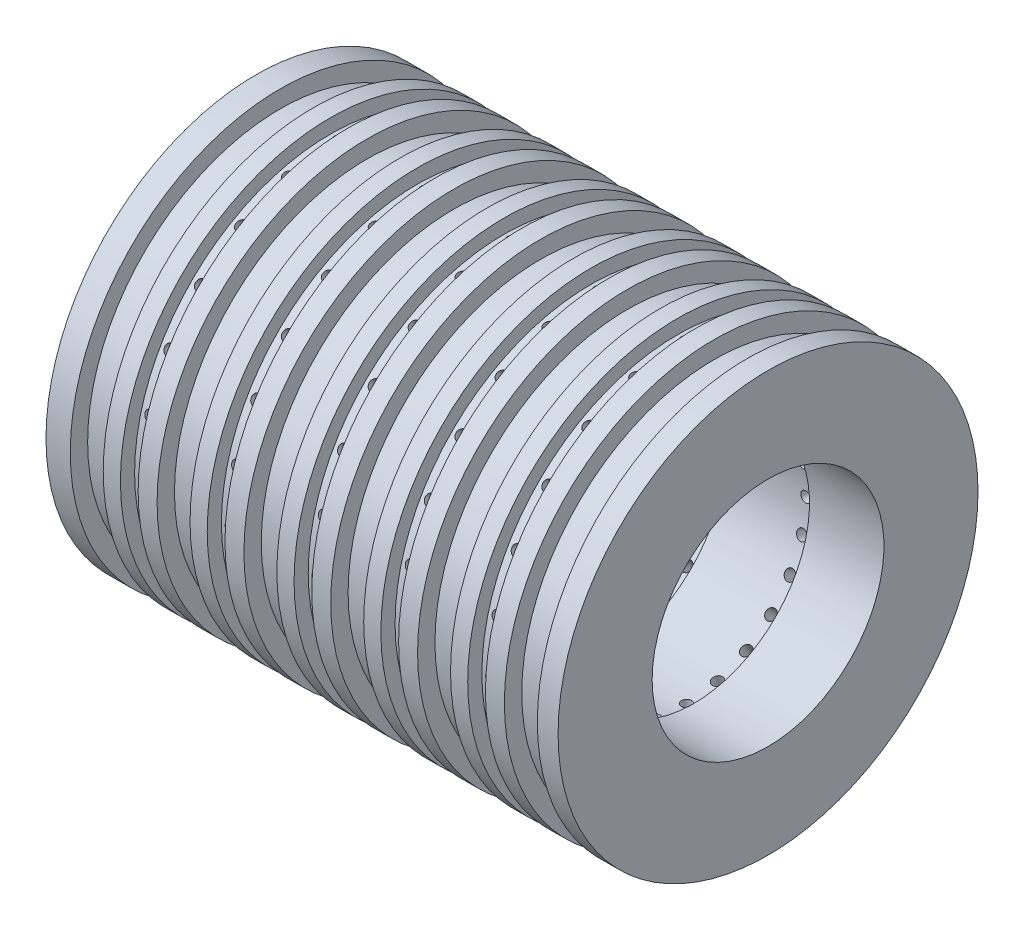
from build123d import *

# Parameters (mm, degrees)
F_69_0_0292_DIAMETER_HOLE1_REACH  = 47.36
F_69_0_0292_DIAMETER_HOLE1_BORE_R = 0.37084
CIRPATTERN1_COUNT                 = 24
CUT_EXTRUDE1_START                = -1.4859
SKETCH11_R                        = 17.8435
SKETCH11_R_2                      = 13.8049
CUT_EXTRUDE1_DEPTH                = 2.3622
LPATTERN1_COUNT                   = 6
LPATTERN1_PITCH                   = 6.223


with BuildPart() as part:
    # Sketch1 → Revolve1 (revolve)
    with BuildSketch(Plane.XY, mode=Mode.PRIVATE) as revolve1_sk:
        with BuildLine():
            Line((-6.477, 9.5758), (-6.477, 15.0495))
            Line((-6.477, 15.0495), (-3.937, 15.0495))
            ThreePointArc((-3.937, 15.0495), (-3.81, 15.1765), (-3.683, 15.0495))
            Line((-3.683, 15.0495), (-1.143, 15.0495))
            Line((-1.143, 15.0495), (-1.143, 14.0335))
            Line((-1.143, 14.0335), (0.127, 14.0335))
            Line((0.127, 14.0335), (0.127, 15.0495))
            Line((0.127, 15.0495), (2.4765, 15.0495))
            ThreePointArc((2.4765, 15.0495), (2.6035, 15.1765), (2.7305, 15.0495))
            Line((2.7305, 15.0495), (5.08, 15.0495))
            Line((5.08, 15.0495), (5.08, 14.0335))
            Line((5.08, 14.0335), (6.35, 14.0335))
            Line((6.35, 14.0335), (6.35, 15.0495))
            Line((6.35, 15.0495), (8.6995, 15.0495))
            ThreePointArc((8.6995, 15.0495), (8.8265, 15.1765), (8.9535, 15.0495))
            Line((8.9535, 15.0495), (11.303, 15.0495))
            Line((11.303, 15.0495), (11.303, 14.0335))
            Line((11.303, 14.0335), (12.573, 14.0335))
            Line((12.573, 14.0335), (12.573, 15.0495))
            Line((12.573, 15.0495), (14.9225, 15.0495))
            ThreePointArc((14.9225, 15.0495), (15.0495, 15.1765), (15.1765, 15.0495))
            Line((15.1765, 15.0495), (17.526, 15.0495))
            Line((17.526, 15.0495), (17.526, 14.0335))
            Line((17.526, 14.0335), (18.796, 14.0335))
            Line((18.796, 14.0335), (18.796, 15.0495))
            Line((18.796, 15.0495), (21.1455, 15.0495))
            ThreePointArc((21.1455, 15.0495), (21.2725, 15.1765), (21.3995, 15.0495))
            Line((21.3995, 15.0495), (23.749, 15.0495))
            Line((23.749, 15.0495), (23.749, 14.0335))
            Line((23.749, 14.0335), (25.019, 14.0335))
            Line((25.019, 14.0335), (25.019, 15.0495))
            Line((25.019, 15.0495), (27.4955, 15.0495))
            ThreePointArc((27.4955, 15.0495), (27.6225, 15.1765), (27.7495, 15.0495))
            Line((27.7495, 15.0495), (30.226, 15.0495))
            Line((30.226, 15.0495), (30.226, 8.3058))
            Line((30.226, 8.3058), (24.892, 8.3058))
            Line((24.892, 8.3058), (24.892, 8.5598))
            Line((24.892, 8.5598), (18.669, 8.5598))
            Line((18.669, 8.5598), (18.669, 8.8138))
            Line((18.669, 8.8138), (12.446, 8.8138))
            Line((12.446, 8.8138), (12.446, 9.0678))
            Line((12.446, 9.0678), (6.223, 9.0678))
            Line((6.223, 9.0678), (6.223, 9.3218))
            Line((6.223, 9.3218), (0, 9.3218))
            Line((0, 9.3218), (0, 9.5758))
            Line((0, 9.5758), (-6.477, 9.5758))
        make_face()
    revolve(revolve1_sk.sketch.rotate(Axis((0, 0, 0), (1, 0, 0)), 90), axis=Axis((0, 0, 0), (1, 0, 0)))

    # 69 _0.0292_ Diameter Hole1 bore → 69 _0.0292_ Diameter Hole1 (cut, up to next)
    with BuildSketch(Plane(origin=(0, 15.0495, 0), x_dir=(1, 0, 0), z_dir=(0, 1, 0)), mode=Mode.PRIVATE) as f_69_0_0292_diameter_hole1_sk1:
        with Locations((24.384, 0)):
            Circle(F_69_0_0292_DIAMETER_HOLE1_BORE_R)
    f_69_0_0292_diameter_hole1_tool1 = extrude(f_69_0_0292_diameter_hole1_sk1.sketch, amount=-F_69_0_0292_DIAMETER_HOLE1_REACH, mode=Mode.PRIVATE) & part.part
    # 69 _0.0292_ Diameter Hole1 bore → 69 _0.0292_ Diameter Hole1 (cut, up to next)
    with BuildSketch(Plane(origin=(0, 15.0495, 0), x_dir=(1, 0, 0), z_dir=(0, 1, 0)), mode=Mode.PRIVATE) as f_69_0_0292_diameter_hole1_sk2:
        with Locations((18.161, 0)):
            Circle(F_69_0_0292_DIAMETER_HOLE1_BORE_R)
    f_69_0_0292_diameter_hole1_tool2 = extrude(f_69_0_0292_diameter_hole1_sk2.sketch, amount=-F_69_0_0292_DIAMETER_HOLE1_REACH, mode=Mode.PRIVATE) & part.part
    # 69 _0.0292_ Diameter Hole1 bore → 69 _0.0292_ Diameter Hole1 (cut, up to next)
    with BuildSketch(Plane(origin=(0, 15.0495, 0), x_dir=(1, 0, 0), z_dir=(0, 1, 0)), mode=Mode.PRIVATE) as f_69_0_0292_diameter_hole1_sk3:
        with Locations((11.938, 0)):
            Circle(F_69_0_0292_DIAMETER_HOLE1_BORE_R)
    f_69_0_0292_diameter_hole1_tool3 = extrude(f_69_0_0292_diameter_hole1_sk3.sketch, amount=-F_69_0_0292_DIAMETER_HOLE1_REACH, mode=Mode.PRIVATE) & part.part
    # 69 _0.0292_ Diameter Hole1 bore → 69 _0.0292_ Diameter Hole1 (cut, up to next)
    with BuildSketch(Plane(origin=(0, 15.0495, 0), x_dir=(1, 0, 0), z_dir=(0, 1, 0)), mode=Mode.PRIVATE) as f_69_0_0292_diameter_hole1_sk4:
        with Locations((5.715, 0)):
            Circle(F_69_0_0292_DIAMETER_HOLE1_BORE_R)
    f_69_0_0292_diameter_hole1_tool4 = extrude(f_69_0_0292_diameter_hole1_sk4.sketch, amount=-F_69_0_0292_DIAMETER_HOLE1_REACH, mode=Mode.PRIVATE) & part.part
    # 69 _0.0292_ Diameter Hole1 bore → 69 _0.0292_ Diameter Hole1 (cut, up to next)
    with BuildSketch(Plane(origin=(0, 15.0495, 0), x_dir=(1, 0, 0), z_dir=(0, 1, 0)), mode=Mode.PRIVATE) as f_69_0_0292_diameter_hole1_sk5:
        with Locations((-0.508, 0)):
            Circle(F_69_0_0292_DIAMETER_HOLE1_BORE_R)
    f_69_0_0292_diameter_hole1_tool5 = extrude(f_69_0_0292_diameter_hole1_sk5.sketch, amount=-F_69_0_0292_DIAMETER_HOLE1_REACH, mode=Mode.PRIVATE) & part.part
    f_69_0_0292_diameter_hole1_1 = f_69_0_0292_diameter_hole1_tool1.solids().sort_by_distance((24.384, 15.0495, 0))[0]
    add(f_69_0_0292_diameter_hole1_1, mode=Mode.SUBTRACT)
    f_69_0_0292_diameter_hole1_2 = f_69_0_0292_diameter_hole1_tool2.solids().sort_by_distance((18.161, 15.0495, 0))[0]
    add(f_69_0_0292_diameter_hole1_2, mode=Mode.SUBTRACT)
    f_69_0_0292_diameter_hole1_3 = f_69_0_0292_diameter_hole1_tool3.solids().sort_by_distance((11.938, 15.0495, 0))[0]
    add(f_69_0_0292_diameter_hole1_3, mode=Mode.SUBTRACT)
    f_69_0_0292_diameter_hole1_4 = f_69_0_0292_diameter_hole1_tool4.solids().sort_by_distance((5.715, 15.0495, 0))[0]
    add(f_69_0_0292_diameter_hole1_4, mode=Mode.SUBTRACT)
    f_69_0_0292_diameter_hole1_5 = f_69_0_0292_diameter_hole1_tool5.solids().sort_by_distance((-0.508, 15.0495, 0))[0]
    add(f_69_0_0292_diameter_hole1_5, mode=Mode.SUBTRACT)
    f_69_0_0292_diameter_hole1 = f_69_0_0292_diameter_hole1_1 + f_69_0_0292_diameter_hole1_2 + f_69_0_0292_diameter_hole1_3 + f_69_0_0292_diameter_hole1_4 + f_69_0_0292_diameter_hole1_5  # 69 _0.0292_ Diameter Hole1 as one shape, for the pattern or mirror that repeats it

    # CirPattern1: 69 _0.0292_ Diameter Hole1 ×24 about axis
    cirpattern1_axis = Axis((0, 0, 0), (-1, 0, 0))
    for i in range(1, CIRPATTERN1_COUNT):
        add(f_69_0_0292_diameter_hole1.rotate(cirpattern1_axis, i * 360 / CIRPATTERN1_COUNT), mode=Mode.SUBTRACT)

    # Sketch11 → Cut-Extrude1 (cut)
    with BuildSketch(Plane(origin=(30.226, 0, 0), x_dir=(0, 0, -1), z_dir=(1, 0, 0)).offset(CUT_EXTRUDE1_START)):
        Circle(SKETCH11_R)
        Circle(SKETCH11_R_2, mode=Mode.SUBTRACT)
    cut_extrude1 = extrude(amount=-CUT_EXTRUDE1_DEPTH, mode=Mode.SUBTRACT)

    # LPattern1: Cut-Extrude1 ×6
    with Locations(*[(-i * LPATTERN1_PITCH, 0, 0) for i in range(1, LPATTERN1_COUNT)]):
        add(cut_extrude1, mode=Mode.SUBTRACT)


solid = part.part
